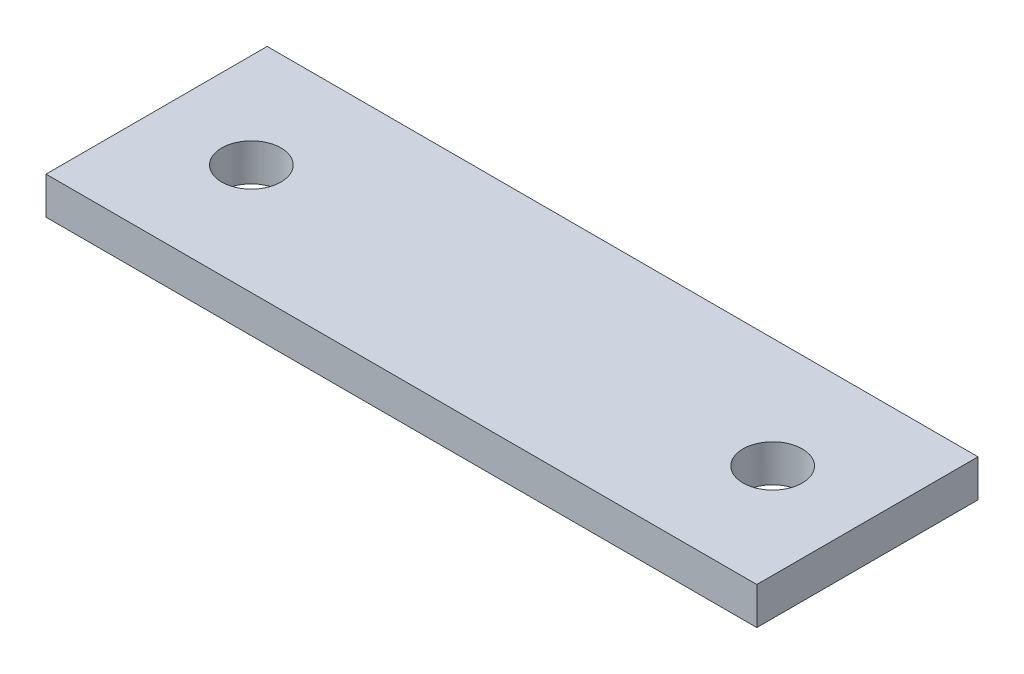
from build123d import *

# Parameters (mm, degrees)
SKETCH1_W                 = 60
SKETCH1_H                 = 18.67
BOSS_EXTRUDE1_DEPTH       = 3.15
F_5_0MM_DOWEL_HOLE1_D     = 5
F_5_0MM_DOWEL_HOLE1_DEPTH = 3.15


with BuildPart() as part:
    # Sketch1 → Boss-Extrude1 (new body)
    with BuildSketch(Plane(origin=(0, 0, 0), x_dir=(1, 0, 0), z_dir=(0, 1, 0))):
        with Locations((30, 9.335)):
            Rectangle(SKETCH1_W, SKETCH1_H)
    extrude(amount=BOSS_EXTRUDE1_DEPTH)

    # Ø5.0mm Dowel Hole1
    with Locations(Plane(origin=(0, 3.15, 0), x_dir=(1, 0, 0), z_dir=(0, 1, 0))):
        with Locations((8, 9.335), (52, 9.335)):
            Hole(F_5_0MM_DOWEL_HOLE1_D / 2, depth=F_5_0MM_DOWEL_HOLE1_DEPTH)


solid = part.part
